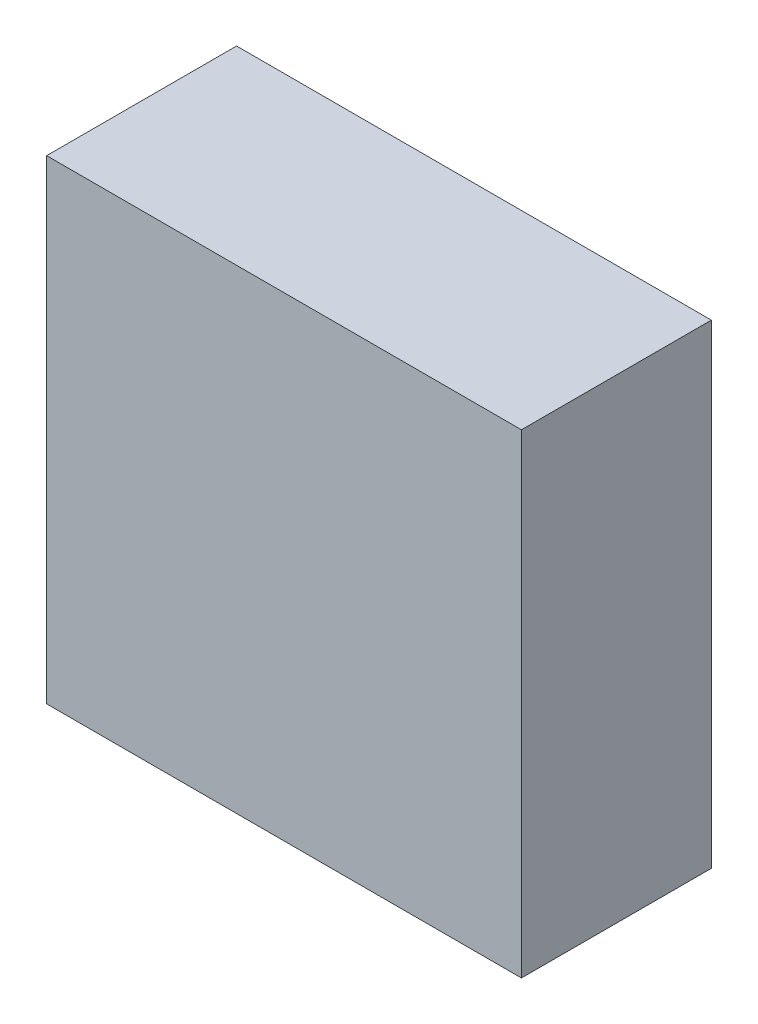
from build123d import *

# Parameters (mm, degrees)
SKETCH1_W           = 15
SKETCH1_H           = 15
BOSS_EXTRUDE1_DEPTH = 6


with BuildPart() as part:
    # Sketch1 → Boss-Extrude1 (new body)
    with BuildSketch(Plane.XY):
        with Locations((7.5, 7.5)):
            Rectangle(SKETCH1_W, SKETCH1_H)
    extrude(amount=BOSS_EXTRUDE1_DEPTH)


solid = part.part
